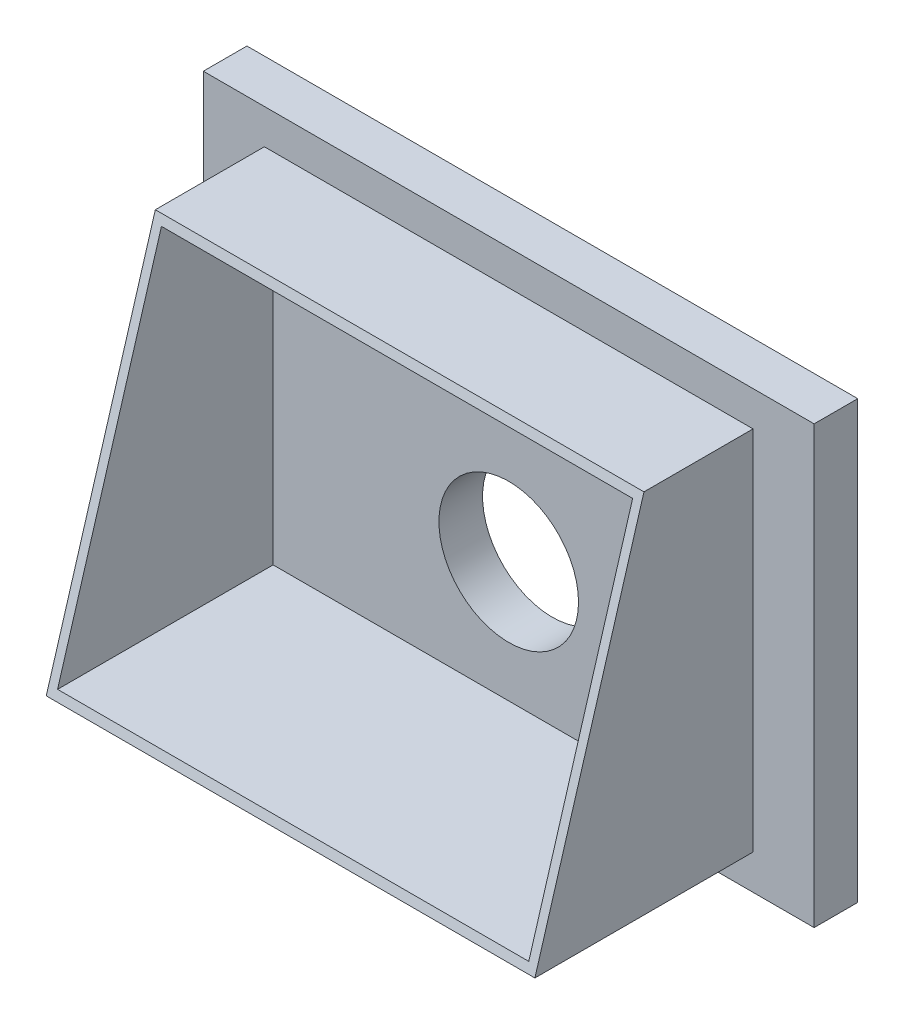
from build123d import *

# Parameters (mm, degrees)
SKETCH1_W               = 700
SKETCH1_H               = 500
BOSS_EXTRUDE1_DEPTH     = 50
SKETCH2_W               = 560
SKETCH2_H               = 420
SKETCH2_W_2             = 540
SKETCH2_H_2             = 400
EXTRUDE_THIN1_DEPTH     = 250
CUT_EXTRUDE5_DEPTH      = 71
CUT_EXTRUDE5_DEPTH_BACK = 631
SKETCH4_R               = 80
CUT_EXTRUDE6_DEPTH      = 51


with BuildPart() as part:
    # Sketch1 → Boss-Extrude1 (new body)
    with BuildSketch(Plane.XY):
        Rectangle(SKETCH1_W, SKETCH1_H)
    extrude(amount=BOSS_EXTRUDE1_DEPTH)

    # Sketch2 → Extrude-Thin1 (add)
    with BuildSketch(Plane.XY.offset(50)):
        Rectangle(SKETCH2_W, SKETCH2_H)
        Rectangle(SKETCH2_W_2, SKETCH2_H_2, mode=Mode.SUBTRACT)
    extrude(amount=EXTRUDE_THIN1_DEPTH)

    # Sketch3 → Cut-Extrude5 (cut, two sides)
    with BuildSketch(Plane.ZY.offset(280)) as cut_extrude5_sk:
        Polygon((300, 210), (175, 210), (300, -210), align=None)
    extrude(amount=CUT_EXTRUDE5_DEPTH, mode=Mode.SUBTRACT)
    extrude(cut_extrude5_sk.sketch, amount=-CUT_EXTRUDE5_DEPTH_BACK, mode=Mode.SUBTRACT)

    # Sketch4 → Cut-Extrude6 (cut, through all)
    with BuildSketch(Plane.XY.offset(50)):
        with Locations((0, -62)):
            Circle(SKETCH4_R)
    extrude(amount=-CUT_EXTRUDE6_DEPTH, mode=Mode.SUBTRACT)


solid = part.part
